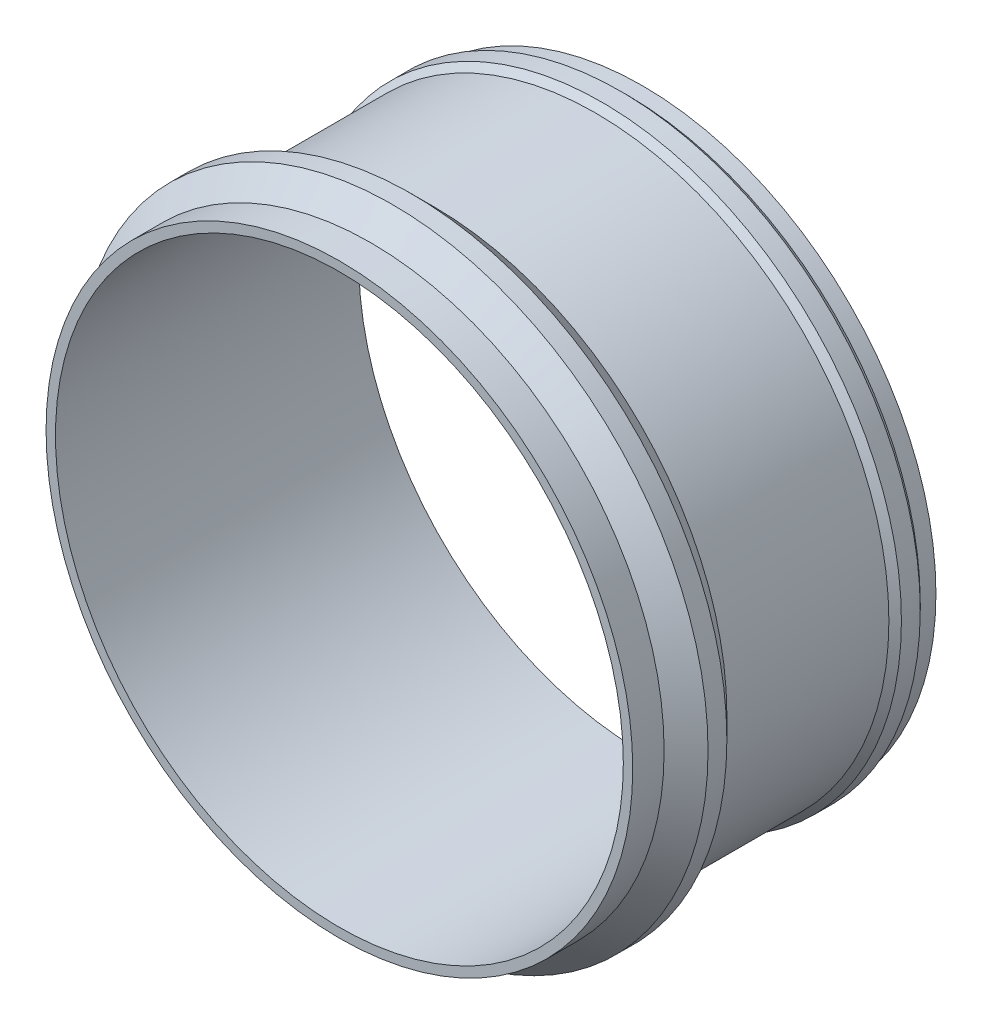
from build123d import *


with BuildPart() as part:
    # Эскиз1 → Повернуть1 (revolve)
    with BuildSketch(Plane(origin=(0, 0, 0), x_dir=(1, 0, 0), z_dir=(0, 1, 0))):
        Polygon((90.5, 120.746712412), (93.5, 120.746712412), (93.5, 115.746712412), (95.5, 113.746712412), (95.5, 107.746712412), (93.5, 105.746712412), (93.5, 54.106712412), (100.5, 47.106712412), (100.5, 41.106712412), (93.5, 34.106712412), (93.5, 24.106712412), (90.5, 24.106712412), align=None)
    revolve(axis=Axis((0, 0, 0), (0, 0, -1)))


solid = part.part
